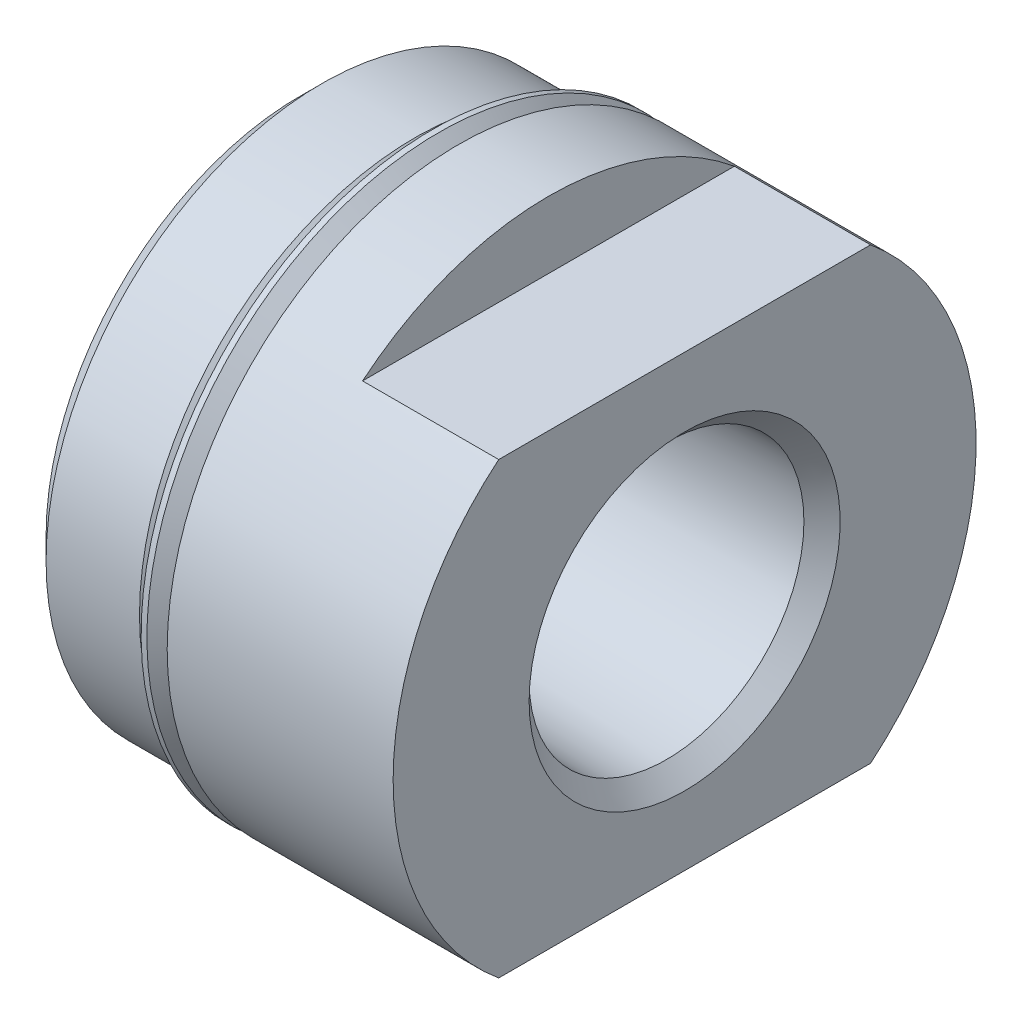
from build123d import *

# Parameters (mm, degrees)
SKETCH3_W          = 81.788
SKETCH3_H          = 40.894
SKETCH3_W_2        = 40.894
SKETCH3_H_2        = 15.748
CUT_EXTRUDE1_DEPTH = 4.7752


with BuildPart() as part:
    # Sketch1 → Revolve1 (revolve)
    with BuildSketch(Plane.XY):
        Polygon((0, 0), (0, 8.90905), (0.762, 9.67105), (4.0386, 9.67105), (4.8006, 8.90905), (5.5626, 8.90905), (5.5626, 10.2235), (13.4874, 10.2235), (13.4874, 0), align=None)
    revolve(axis=Axis((13.4874, 0, 0), (-1, 0, 0)))

    # Sketch2 → Cut-Revolve1 (revolve, cut)
    with BuildSketch(Plane.XY):
        Polygon((0, 0), (0, 4.3688), (-1.588923892, 4.3688), (12.852387191, 4.819651116), (13.4874, 5.454663925), (13.4874, 0), align=None)
    revolve(axis=Axis((13.4874, 0, 0), (-1, 0, 0)), mode=Mode.SUBTRACT)

    # Sketch3 → Cut-Extrude1 (cut)
    with BuildSketch(Plane(origin=(13.4874, 0, 0), x_dir=(0, 0, -1), z_dir=(1, 0, 0))):
        Rectangle(SKETCH3_W, SKETCH3_H)
        Rectangle(SKETCH3_W_2, SKETCH3_H_2, mode=Mode.SUBTRACT)
    extrude(amount=-CUT_EXTRUDE1_DEPTH, mode=Mode.SUBTRACT)

    # Sketch4 → Revolve2 (revolve)
    with BuildSketch(Plane.XY):
        with BuildLine():
            Line((4.64794893, 10.139331804), (5.440112806, 9.347167928))
            ThreePointArc((5.440112806, 9.347167928), (5.477310245, 9.257365367), (5.440112806, 9.167562806))
            Line((5.440112806, 9.167562806), (5.1816, 8.90905))
            Line((5.1816, 8.90905), (4.8006, 8.90905))
            Line((4.8006, 8.90905), (4.8006, 8.65505))
            Line((4.8006, 8.65505), (5.5626, 8.65505))
            Line((5.5626, 8.65505), (5.5626, 9.51204893))
            Line((5.5626, 9.51204893), (4.85114893, 10.2235))
            Line((4.85114893, 10.2235), (4.64794893, 10.2235))
            Line((4.64794893, 10.2235), (4.64794893, 10.139331804))
        make_face()
    revolve(axis=Axis((5.5626, 0, 0), (-1, 0, 0)))


solid = part.part
